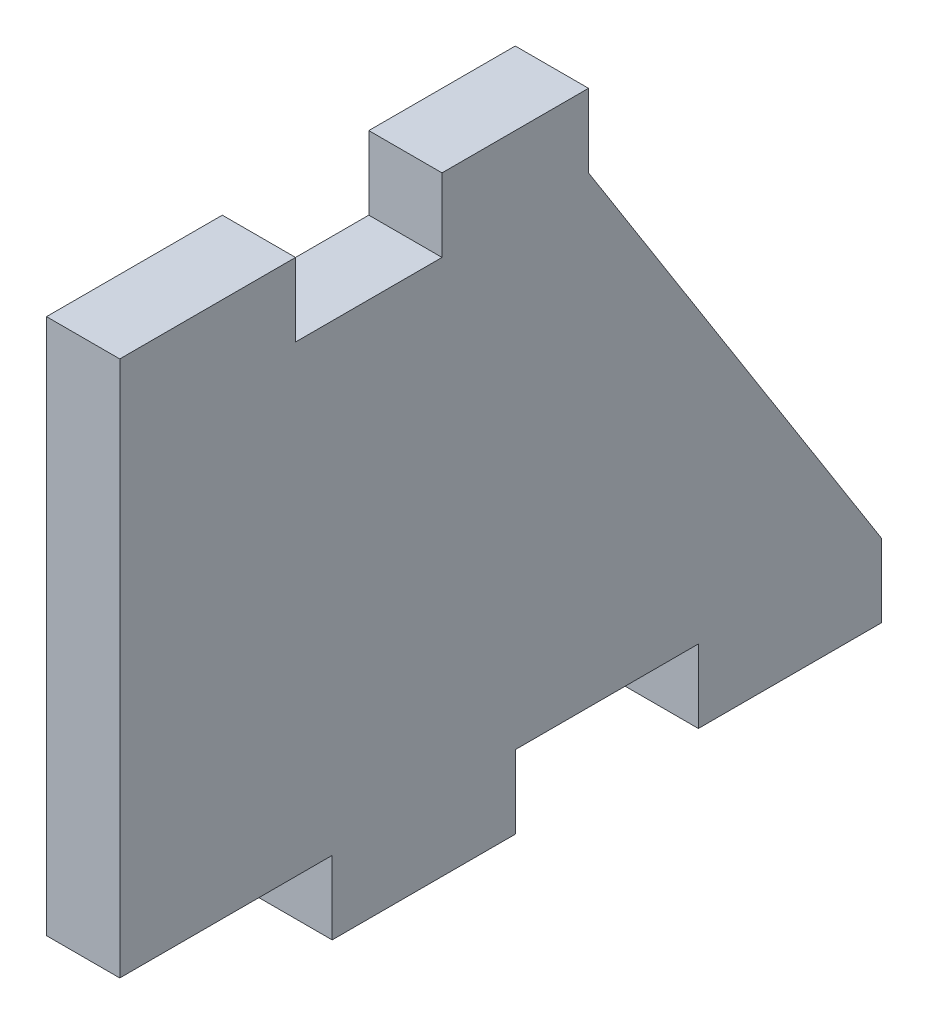
from build123d import *

# Parameters (mm, degrees)
SKETCH1_W           = 63.5
SKETCH1_H           = 40.132
BOSS_EXTRUDE1_DEPTH = 6.35
CUT_EXTRUDE1_DEPTH  = 7.35
SKETCH3_W           = 12.7
SKETCH3_H           = 6.35
SKETCH3_W_2         = 15.875
BOSS_EXTRUDE2_DEPTH = 6.35
SKETCH4_W           = 2.54
SKETCH4_H           = 37.084
BOSS_EXTRUDE7_DEPTH = 6.35
SKETCH6_W           = 2.54
SKETCH6_H           = 46.482
BOSS_EXTRUDE8_DEPTH = 6.35


with BuildPart() as part:
    # Sketch1 → Boss-Extrude1 (new body)
    with BuildSketch(Plane(origin=(0, 0, 0), x_dir=(0, 0, -1), z_dir=(1, 0, 0))):
        Rectangle(SKETCH1_W, SKETCH1_H)
    extrude(amount=BOSS_EXTRUDE1_DEPTH)

    # Sketch2 → Cut-Extrude1 (cut, through all)
    with BuildSketch(Plane.ZY):
        Polygon((-31.75, -20.066), (-31.75, 20.066), (-6.35, 20.066), align=None)
    extrude(amount=-CUT_EXTRUDE1_DEPTH, mode=Mode.SUBTRACT)

    # Sketch3 → Boss-Extrude2 (add, through all)
    with BuildSketch(Plane.ZY):
        with Locations((25.4, 23.241)):
            Rectangle(SKETCH3_W, SKETCH3_H)
        with Locations((0, 23.241)):
            Rectangle(SKETCH3_W, SKETCH3_H)
        with Locations((7.9375, -23.241)):
            Rectangle(SKETCH3_W_2, SKETCH3_H)
        with Locations((-23.8125, -23.241)):
            Rectangle(SKETCH3_W_2, SKETCH3_H)
    extrude(amount=-BOSS_EXTRUDE2_DEPTH)

    # Sketch4 → Boss-Extrude7 (add)
    with BuildSketch(Plane.ZY):
        with Locations((30.48, 2.667)):
            Rectangle(SKETCH4_W, SKETCH4_H)
    extrude(amount=-BOSS_EXTRUDE7_DEPTH)

    # Sketch6 → Boss-Extrude8 (add)
    with BuildSketch(Plane(origin=(6.35, 0, 0), x_dir=(0, 0, -1), z_dir=(1, 0, 0))):
        with Locations((-33.02, 3.175)):
            Rectangle(SKETCH6_W, SKETCH6_H)
    extrude(amount=-BOSS_EXTRUDE8_DEPTH)


solid = part.part
